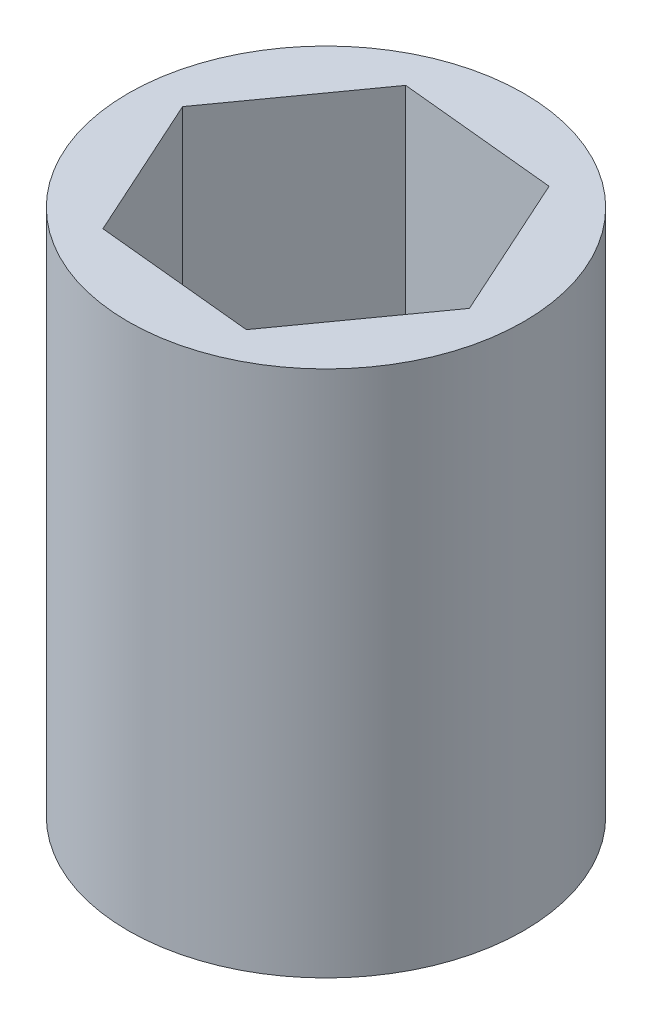
from build123d import *

# Parameters (mm, degrees)
SKETCH1_R           = 19.05
BOSS_EXTRUDE1_DEPTH = 50.8
CUT_EXTRUDE1_DEPTH  = 50.8


with BuildPart() as part:
    # Sketch1 → Boss-Extrude1 (new body)
    with BuildSketch(Plane(origin=(0, 0, 0), x_dir=(1, 0, 0), z_dir=(0, 1, 0))):
        Circle(SKETCH1_R)
    extrude(amount=BOSS_EXTRUDE1_DEPTH)

    # Sketch2 → Cut-Extrude1 (cut)
    with BuildSketch(Plane.XZ):
        Polygon((-15.323636661, -1.510781079), (-6.353443536, -14.026049167), (8.970193125, -12.515268087), (15.323636661, 1.510781079), (6.353443536, 14.026049167), (-8.970193125, 12.515268087), align=None)
    extrude(amount=-CUT_EXTRUDE1_DEPTH, mode=Mode.SUBTRACT)


solid = part.part
